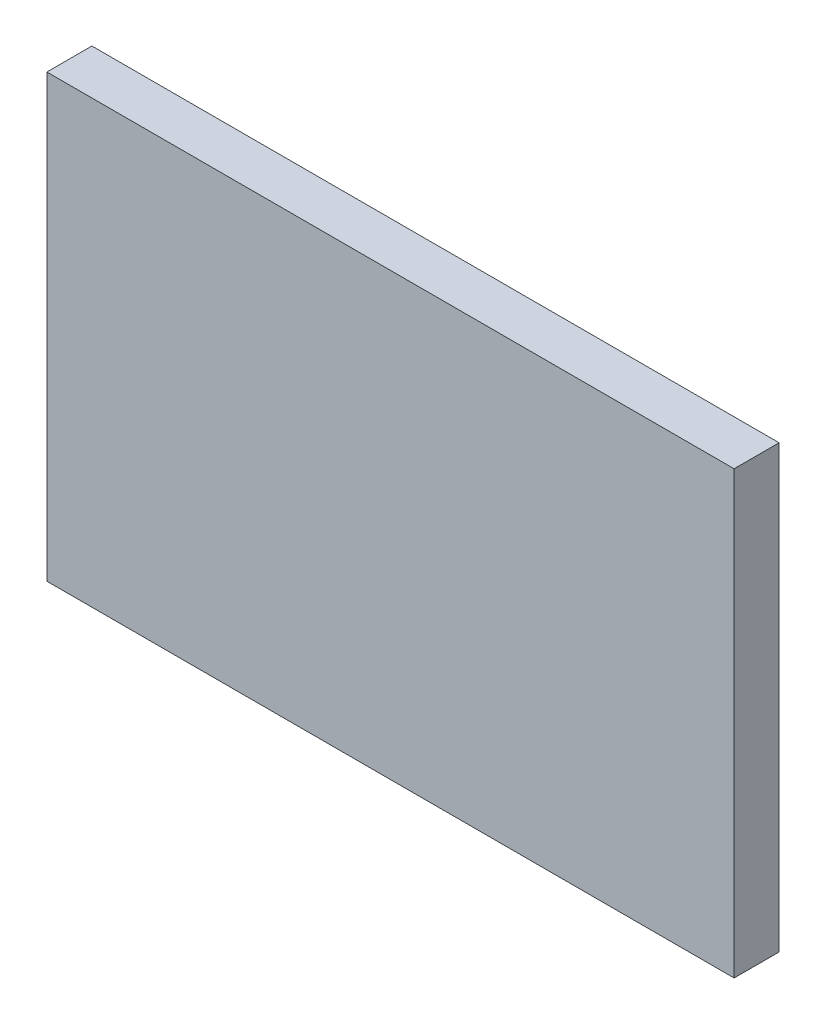
from build123d import *

# Parameters (mm, degrees)
SKETCH1_W           = 189.992
SKETCH1_H           = 121.92
BOSS_EXTRUDE1_DEPTH = 12.446


with BuildPart() as part:
    # Sketch1 → Boss-Extrude1 (new body)
    with BuildSketch(Plane.XY):
        Rectangle(SKETCH1_W, SKETCH1_H)
    extrude(amount=BOSS_EXTRUDE1_DEPTH)


solid = part.part
